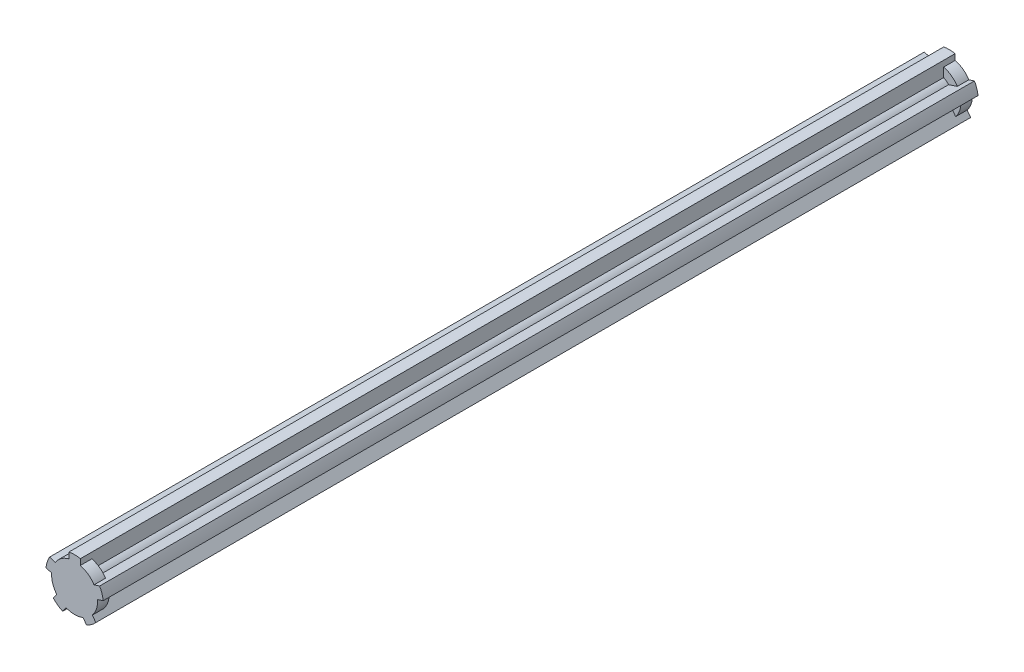
from build123d import *

# Parameters (mm, degrees)
SKETCH1_R           = 3.175
BOSS_EXTRUDE1_DEPTH = 96.52
SKETCH2_R           = 5.08
BOSS_EXTRUDE2_DEPTH = 2.54
BOSS_EXTRUDE3_DEPTH = 193.04


with BuildPart() as part:
    # Sketch1 → Boss-Extrude1 (new body)
    with BuildSketch(Plane.XY):
        Circle(SKETCH1_R)
    boss_extrude1 = extrude(amount=BOSS_EXTRUDE1_DEPTH)

    # Sketch2 → Boss-Extrude2 (add)
    with BuildSketch(Plane.XY.offset(96.52)):
        Circle(SKETCH2_R)
    boss_extrude2 = extrude(amount=-BOSS_EXTRUDE2_DEPTH)

    # Mirror1: Boss-Extrude1, Boss-Extrude2 across plane
    add(boss_extrude1.mirror(Plane.XY))
    add(boss_extrude2.mirror(Plane.XY))

    # Sketch3 → Boss-Extrude3 (add, through all)
    with BuildSketch(Plane(origin=(0, 0, -96.52), x_dir=(-1, 0, 0), z_dir=(0, 0, -1))):
        with BuildLine():
            Line((-1.27, 4.91868885), (-1.27, 2.199704526))
            Line((-1.27, 2.199704526), (1.27, 2.199704526))
            Line((1.27, 2.199704526), (1.27, 4.91868885))
            Line((1.27, 4.91868885), (1.27, 6.221703947))
            ThreePointArc((1.27, 6.221703947), (0, 6.35), (-1.27, 6.221703947))
            Line((-1.27, 6.221703947), (-1.27, 4.91868885))
        make_face()
        with BuildLine():
            Line((1.69959174, 1.887587857), (2.484494906, -0.528095695))
            Line((2.484494906, -0.528095695), (5.070402665, 0.312116669))
            Line((5.070402665, 0.312116669), (6.309643664, 0.714770478))
            ThreePointArc((6.309643664, 0.714770478), (6.039208878, 1.962257914), (5.524740498, 3.130454029))
            Line((5.524740498, 3.130454029), (4.285499499, 2.72780022))
            Line((4.285499499, 2.72780022), (1.69959174, 1.887587857))
        make_face()
        with BuildLine():
            Line((2.320405462, -1.033111073), (0.265502297, -2.526085614))
            Line((0.265502297, -2.526085614), (1.863681184, -4.72579014))
            Line((1.863681184, -4.72579014), (2.629574241, -5.779951497))
            ThreePointArc((2.629574241, -5.779951497), (3.732436352, -5.137257914), (4.684477407, -4.286976956))
            Line((4.684477407, -4.286976956), (3.918584349, -3.232815599))
            Line((3.918584349, -3.232815599), (2.320405462, -1.033111073))
        make_face()
        with BuildLine():
            Line((-0.265502297, -2.526085614), (-2.320405462, -1.033111073))
            Line((-2.320405462, -1.033111073), (-3.918584349, -3.232815599))
            Line((-3.918584349, -3.232815599), (-4.684477407, -4.286976956))
            ThreePointArc((-4.684477407, -4.286976956), (-3.732436352, -5.137257914), (-2.629574241, -5.779951497))
            Line((-2.629574241, -5.779951497), (-1.863681184, -4.72579014))
            Line((-1.863681184, -4.72579014), (-0.265502297, -2.526085614))
        make_face()
        with BuildLine():
            Line((-2.484494906, -0.528095695), (-1.69959174, 1.887587857))
            Line((-1.69959174, 1.887587857), (-4.285499499, 2.72780022))
            Line((-4.285499499, 2.72780022), (-5.524740498, 3.130454029))
            ThreePointArc((-5.524740498, 3.130454029), (-6.039208878, 1.962257914), (-6.309643664, 0.714770478))
            Line((-6.309643664, 0.714770478), (-5.070402665, 0.312116669))
            Line((-5.070402665, 0.312116669), (-2.484494906, -0.528095695))
        make_face()
    extrude(amount=-BOSS_EXTRUDE3_DEPTH)


solid = part.part
